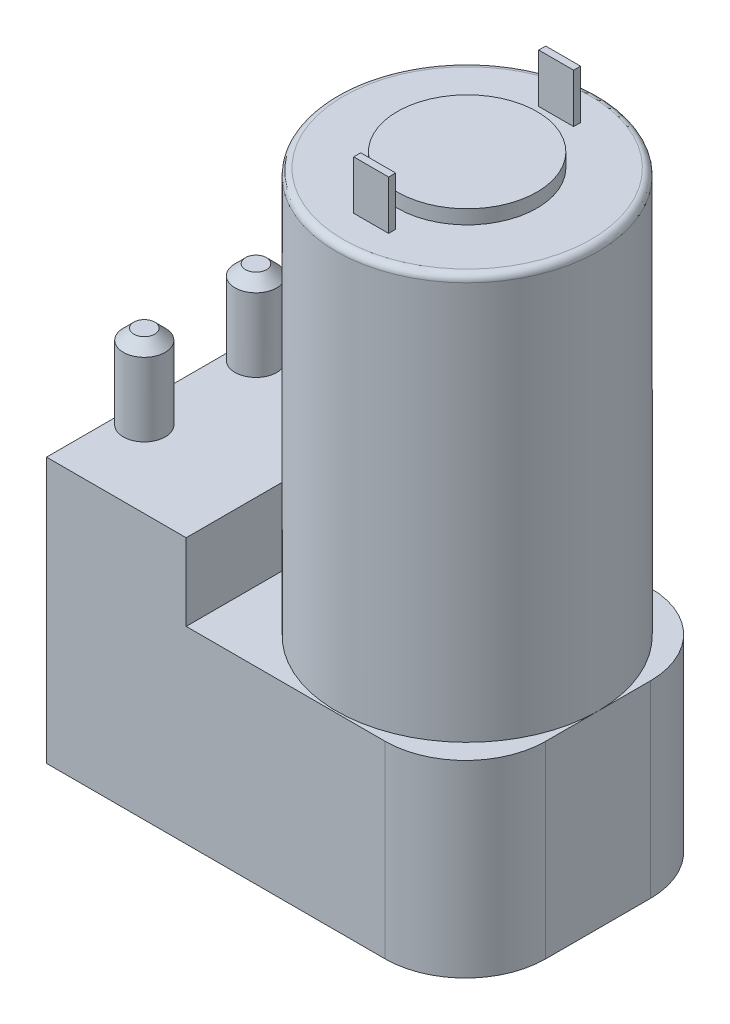
from build123d import *

# Parameters (mm, degrees)
EXTRUSION1_DEPTH = 27
ESQUISSE2_W      = 20
ESQUISSE2_H      = 38
EXTRUSION2_DEPTH = 11
ESQUISSE3_R      = 18.75
EXTRUSION3_DEPTH = 58
ESQUISSE4_R      = 10
EXTRUSION4_DEPTH = 2
ESQUISSE5_R      = 3
EXTRUSION5_DEPTH = 12
CHANFREIN1_SIZE  = 1.5
CONG_1_R         = 1
ESQUISSE6_W      = 5
ESQUISSE6_H      = 1
EXTRUSION6_DEPTH = 7


with BuildPart() as part:
    # Esquisse1 → Extrusion1 (new body)
    with BuildSketch(Plane(origin=(0, 0, 0), x_dir=(1, 0, 0), z_dir=(0, 1, 0))):
        with BuildLine():
            Line((0, 0), (48.5, 0))
            ThreePointArc((48.5, 0), (56.631727984, 3.368272016), (60, 11.5))
            Line((60, 11.5), (60, 26.5))
            ThreePointArc((60, 26.5), (56.631727984, 34.631727984), (48.5, 38))
            Line((48.5, 38), (0, 38))
            Line((0, 38), (0, 0))
        make_face()
    extrude(amount=EXTRUSION1_DEPTH)

    # Esquisse2 → Extrusion2 (add)
    with BuildSketch(Plane(origin=(0, 27, 0), x_dir=(1, 0, 0), z_dir=(0, 1, 0))):
        with Locations((10, 19)):
            Rectangle(ESQUISSE2_W, ESQUISSE2_H)
    extrude(amount=EXTRUSION2_DEPTH)

    # Esquisse3 → Extrusion3 (add)
    with BuildSketch(Plane(origin=(0, 27, 0), x_dir=(1, 0, 0), z_dir=(0, 1, 0))):
        with Locations((41.25, 19)):
            Circle(ESQUISSE3_R)
    extrude(amount=EXTRUSION3_DEPTH)

    # Esquisse4 → Extrusion4 (add)
    with BuildSketch(Plane(origin=(0, 85, 0), x_dir=(1, 0, 0), z_dir=(0, 1, 0))):
        with Locations((41.25, 19)):
            Circle(ESQUISSE4_R)
    extrude(amount=EXTRUSION4_DEPTH)

    # Esquisse5 → Extrusion5 (add)
    with BuildSketch(Plane(origin=(0, 38, 0), x_dir=(1, 0, 0), z_dir=(0, 1, 0))):
        with Locations((3, 27)):
            Circle(ESQUISSE5_R)
        with Locations((3, 11)):
            Circle(ESQUISSE5_R)
    extrude(amount=EXTRUSION5_DEPTH)

    # Chanfrein1
    chanfrein1_edges = [part.edges().sort_by_distance(p)[0] for p in [
        (0, 50, -27),
        (0, 50, -11),
    ]]
    chamfer(chanfrein1_edges, length=CHANFREIN1_SIZE)

    # Congé1
    cong_1_edges = [part.edges().sort_by_distance(p)[0] for p in [
        (22.5, 85, -19),
    ]]
    fillet(cong_1_edges, radius=CONG_1_R)

    # Esquisse6 → Extrusion6 (add)
    with BuildSketch(Plane(origin=(0, 85, 0), x_dir=(1, 0, 0), z_dir=(0, 1, 0))):
        with Locations((41.25, 32.25)):
            Rectangle(ESQUISSE6_W, ESQUISSE6_H)
        with Locations((41.25, 5.75)):
            Rectangle(ESQUISSE6_W, ESQUISSE6_H)
    extrude(amount=EXTRUSION6_DEPTH)


solid = part.part
